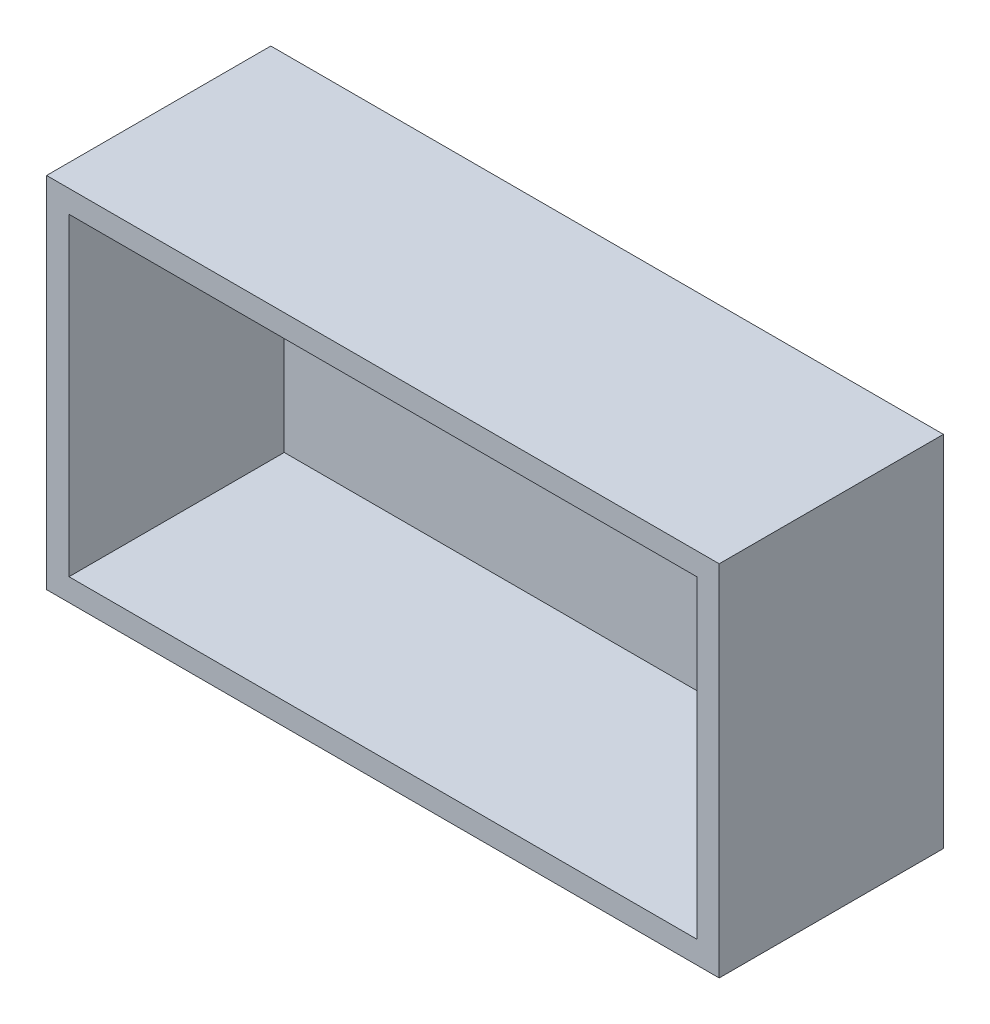
from build123d import *

# Parameters (mm, degrees)
SKETCH1_W           = 150
SKETCH1_H           = 80
BOSS_EXTRUDE1_DEPTH = 50
SKETCH2_W           = 140
SKETCH2_H           = 70
CUT_EXTRUDE1_DEPTH  = 48


with BuildPart() as part:
    # Sketch1 → Boss-Extrude1 (new body)
    with BuildSketch(Plane.XY):
        with Locations((-3.955696203, -29.873417722)):
            Rectangle(SKETCH1_W, SKETCH1_H)
    extrude(amount=BOSS_EXTRUDE1_DEPTH)

    # Sketch2 → Cut-Extrude1 (cut)
    with BuildSketch(Plane.XY.offset(50)):
        with Locations((-3.955696203, -29.873417722)):
            Rectangle(SKETCH2_W, SKETCH2_H)
    extrude(amount=-CUT_EXTRUDE1_DEPTH, mode=Mode.SUBTRACT)


solid = part.part
